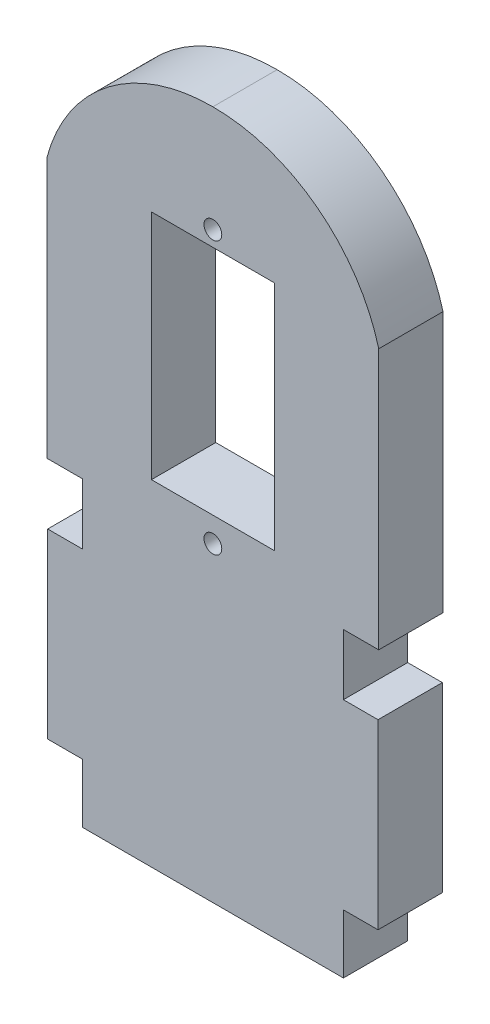
from build123d import *

# Parameters (mm, degrees)
SKETCH3_R           = 0.9
SKETCH3_W           = 12.417
SKETCH3_H           = 23.449530758
BOSS_EXTRUDE6_DEPTH = 6.5


with BuildPart() as part:
    # Sketch3 → Boss-Extrude6 (new body)
    with BuildSketch(Plane.XY):
        with BuildLine():
            Line((26.008786765, 76.166270115), (26.008786765, 49.799855834))
            Line((26.008786765, 49.799855834), (29.580786765, 49.799855834))
            Line((29.580786765, 49.799855834), (29.580786765, 43.649855834))
            Line((29.580786765, 43.649855834), (26.080786765, 43.649855834))
            Line((26.080786765, 43.649855834), (26.080786765, 25.249855834))
            Line((26.080786765, 25.249855834), (29.580786765, 25.249855834))
            Line((29.580786765, 25.249855834), (29.580786765, 25.206855834))
            Line((29.580786765, 25.206855834), (29.580786765, 19.279855834))
            Line((29.580786765, 19.279855834), (55.980786765, 19.279855834))
            Line((55.980786765, 19.279855834), (55.980786765, 25.249855834))
            Line((55.980786765, 25.249855834), (59.480786765, 25.249855834))
            Line((59.480786765, 25.249855834), (59.480786765, 43.649855834))
            Line((59.480786765, 43.649855834), (55.980786765, 43.649855834))
            Line((55.980786765, 43.649855834), (55.980786765, 49.799855834))
            Line((55.980786765, 49.799855834), (59.552786765, 49.799855834))
            Line((59.552786765, 49.799855834), (59.552786765, 76.166270115))
            ThreePointArc((59.552786765, 76.166270115), (53.346414701, 85.422492969), (42.780786765, 88.967097604))
            ThreePointArc((42.780786765, 88.967097604), (32.215158829, 85.422492969), (26.008786765, 76.166270115))
        make_face()
        with Locations((42.780786765, 50.712301369)):
            Circle(SKETCH3_R, mode=Mode.SUBTRACT)
        with Locations((42.780786765, 78.212301369)):
            Circle(SKETCH3_R, mode=Mode.SUBTRACT)
        with Locations((42.780786765, 64.937066748)):
            Rectangle(SKETCH3_W, SKETCH3_H, mode=Mode.SUBTRACT)
    extrude(amount=BOSS_EXTRUDE6_DEPTH)


solid = part.part
